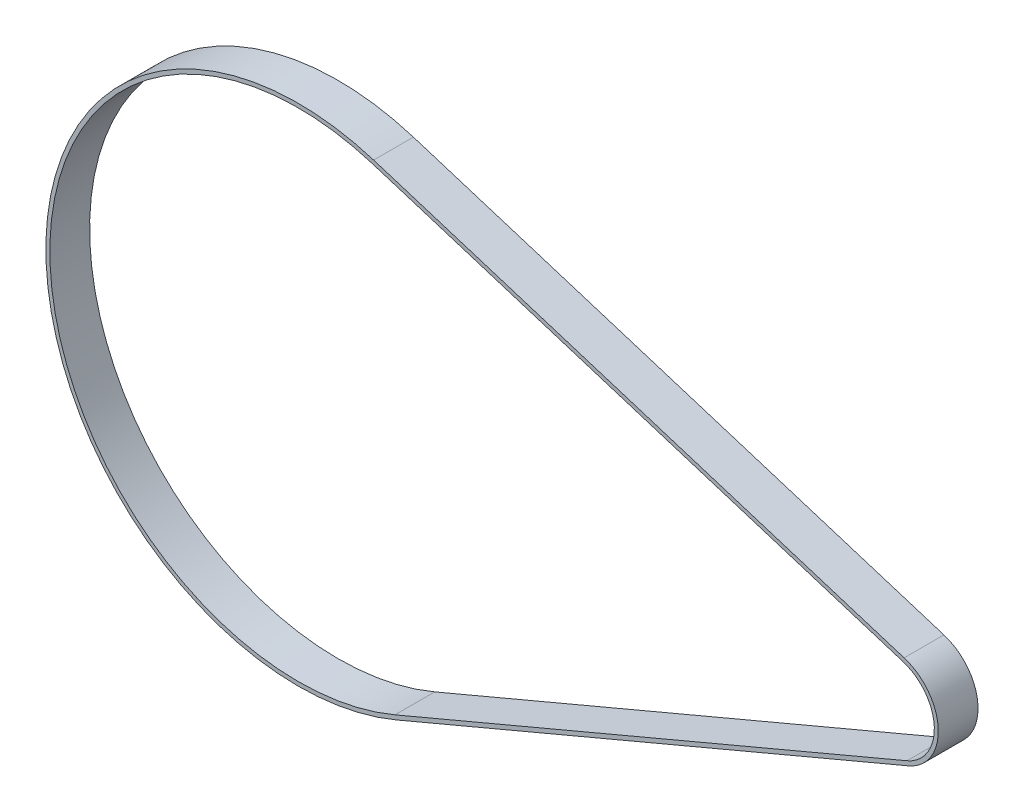
from build123d import *

# Parameters (mm, degrees)
EXTRUDE_THIN1_DEPTH = 10


with BuildPart() as part:
    # Sketch2 → Extrude-Thin1 (new, symmetric)
    with BuildSketch(Plane.XY):
        with BuildLine():
            Line((307.032357419, -8.186158212), (49.412628252, -116.993128726))
            ThreePointArc((49.412628252, -116.993128726), (-126.851829657, -6.132969312), (37.895894766, 121.214277872))
            Line((37.895894766, 121.214277872), (304.810625368, 37.767239124))
            ThreePointArc((304.810625368, 37.767239124), (321.971415958, 15.566514244), (307.032357419, -8.186158212))
        make_face()
        with BuildLine():
            Line((306.254205793, -6.343746736), (48.634476626, -115.15071725))
            ThreePointArc((48.634476626, -115.15071725), (-124.854163049, -6.036387118), (37.299109021, 119.305391606))
            Line((37.299109021, 119.305391606), (304.213839624, 35.858352858))
            ThreePointArc((304.213839624, 35.858352858), (319.973749349, 15.46993205), (306.254205793, -6.343746736))
        make_face(mode=Mode.SUBTRACT)
    extrude(amount=EXTRUDE_THIN1_DEPTH, both=True)


solid = part.part
